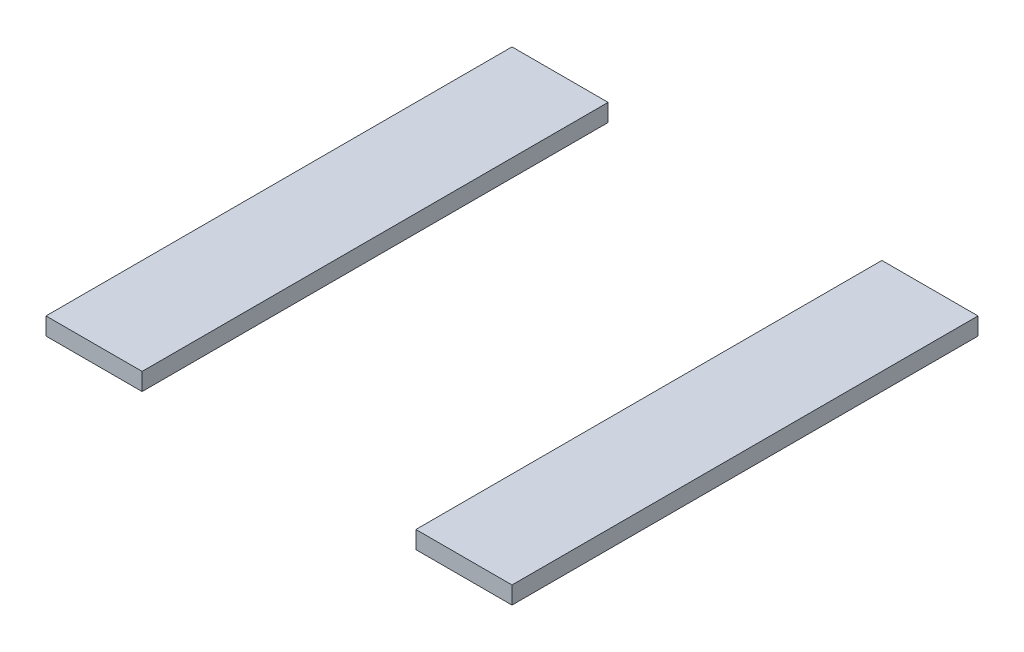
from build123d import *

# Parameters (mm, degrees)
SKETCH1_W             = 16.5
SKETCH1_H             = 80
BOSS_EXTRUDE1_DEPTH   = 3
BOSS_EXTRUDE1_2_DEPTH = 3


with BuildPart() as part:
    # Sketch1 → Boss-Extrude1 (new body)
    with BuildSketch(Plane(origin=(0, 0, 0), x_dir=(1, 0, 0), z_dir=(0, 1, 0))):
        with Locations((8.25, 40)):
            Rectangle(SKETCH1_W, SKETCH1_H)
    extrude(amount=BOSS_EXTRUDE1_DEPTH)


with BuildPart() as body_2:
    # Sketch1 → Boss-Extrude1 2 (new body)
    with BuildSketch(Plane(origin=(0, 0, 0), x_dir=(1, 0, 0), z_dir=(0, 1, 0))):
        with Locations((71.75, 40)):
            Rectangle(SKETCH1_W, SKETCH1_H)
    extrude(amount=BOSS_EXTRUDE1_2_DEPTH)


solid = Compound([part.part, body_2.part])
